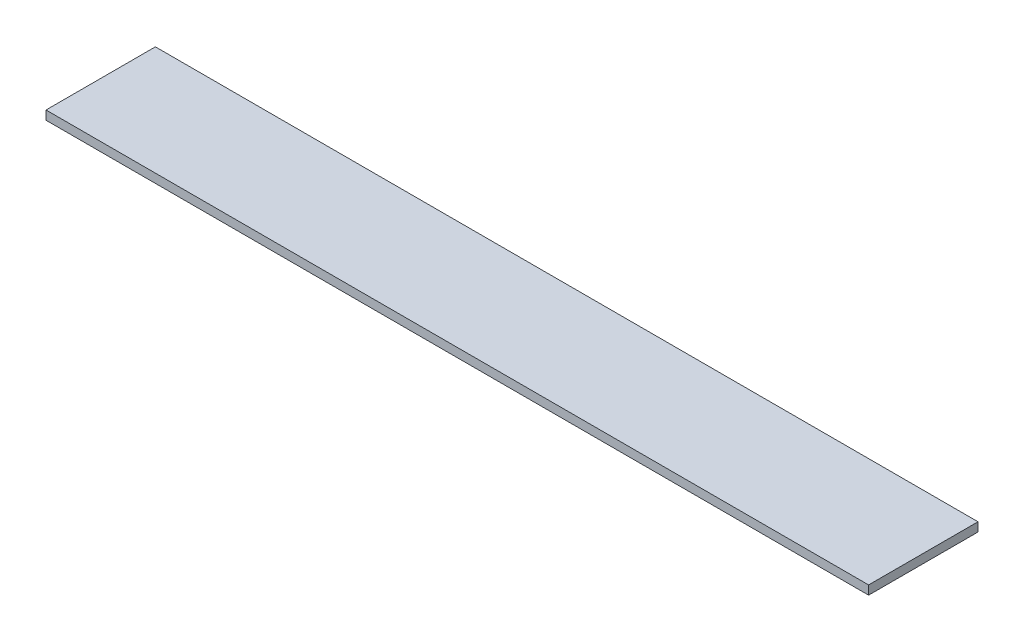
from build123d import *

# Parameters (mm, degrees)
SKETCH1_W           = 92.5
SKETCH1_H           = 12.3
BOSS_EXTRUDE1_DEPTH = 1


with BuildPart() as part:
    # Sketch1 → Boss-Extrude1 (new body)
    with BuildSketch(Plane(origin=(0, 0, 0), x_dir=(1, 0, 0), z_dir=(0, 1, 0))):
        with Locations((46.25, 6.15)):
            Rectangle(SKETCH1_W, SKETCH1_H)
    extrude(amount=BOSS_EXTRUDE1_DEPTH)


solid = part.part
